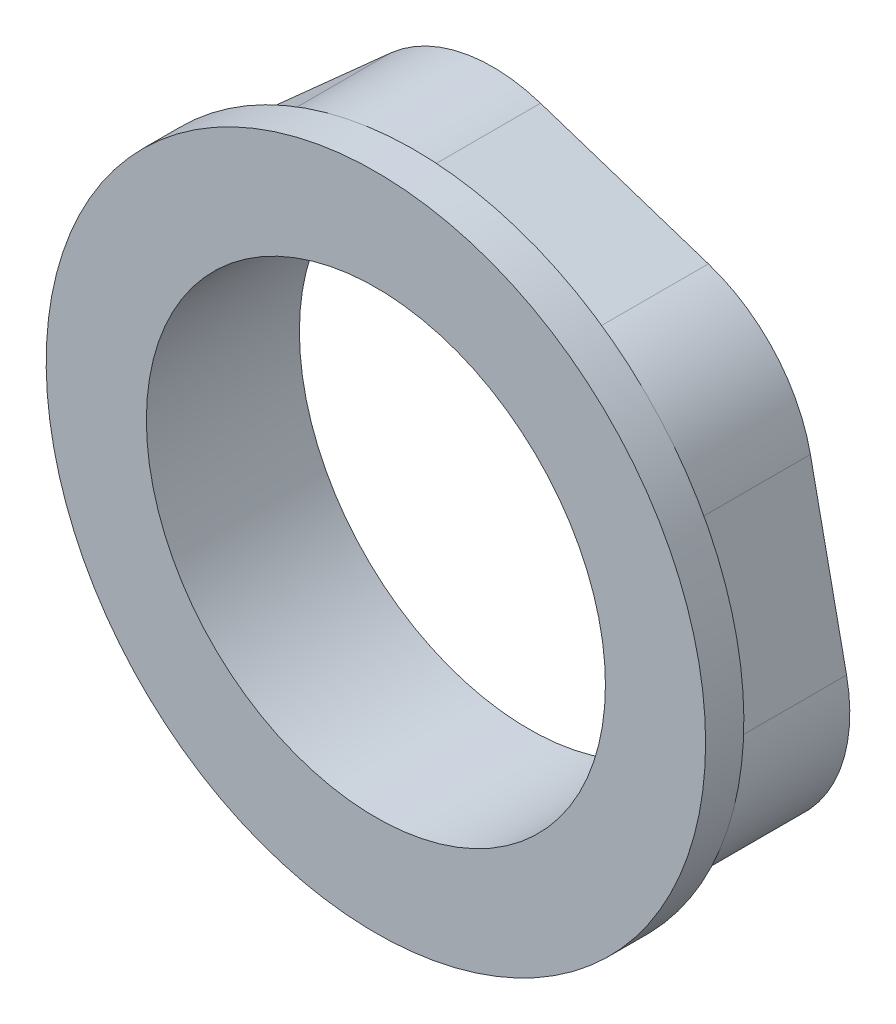
from build123d import *

# Parameters (mm, degrees)
SKETCH1_R           = 15
BOSS_EXTRUDE1_DEPTH = 7.5
FILLET1_R           = 10
SKETCH5_R           = 21.547005384
SKETCH5_R_2         = 15
BOSS_EXTRUDE2_DEPTH = 2.5


with BuildPart() as part:
    # Sketch1 → Boss-Extrude1 (new body)
    with BuildSketch(Plane.XY):
        Polygon((4.726541348, -22.605157381), (21.939911222, -7.209273811), (17.213369874, 15.39588357), (-4.726541348, 22.605157381), (-21.939911222, 7.209273811), (-17.213369874, -15.39588357), align=None)
        Circle(SKETCH1_R, mode=Mode.SUBTRACT)
    extrude(amount=BOSS_EXTRUDE1_DEPTH)

    # Fillet1
    fillet1_edges = [part.edges().sort_by_distance(p)[0] for p in [
        (-17.213369874, -15.39588357, 3.75),
        (-21.939911222, 7.209273811, 3.75),
        (-4.726541348, 22.605157381, 3.75),
        (17.213369874, 15.39588357, 3.75),
        (21.939911222, -7.209273811, 3.75),
        (4.726541348, -22.605157381, 3.75),
    ]]
    fillet(fillet1_edges, radius=FILLET1_R)

    # Sketch5 → Boss-Extrude2 (add)
    with BuildSketch(Plane.XY.offset(7.5)):
        Circle(SKETCH5_R)
        Circle(SKETCH5_R_2, mode=Mode.SUBTRACT)
    extrude(amount=BOSS_EXTRUDE2_DEPTH)


solid = part.part
